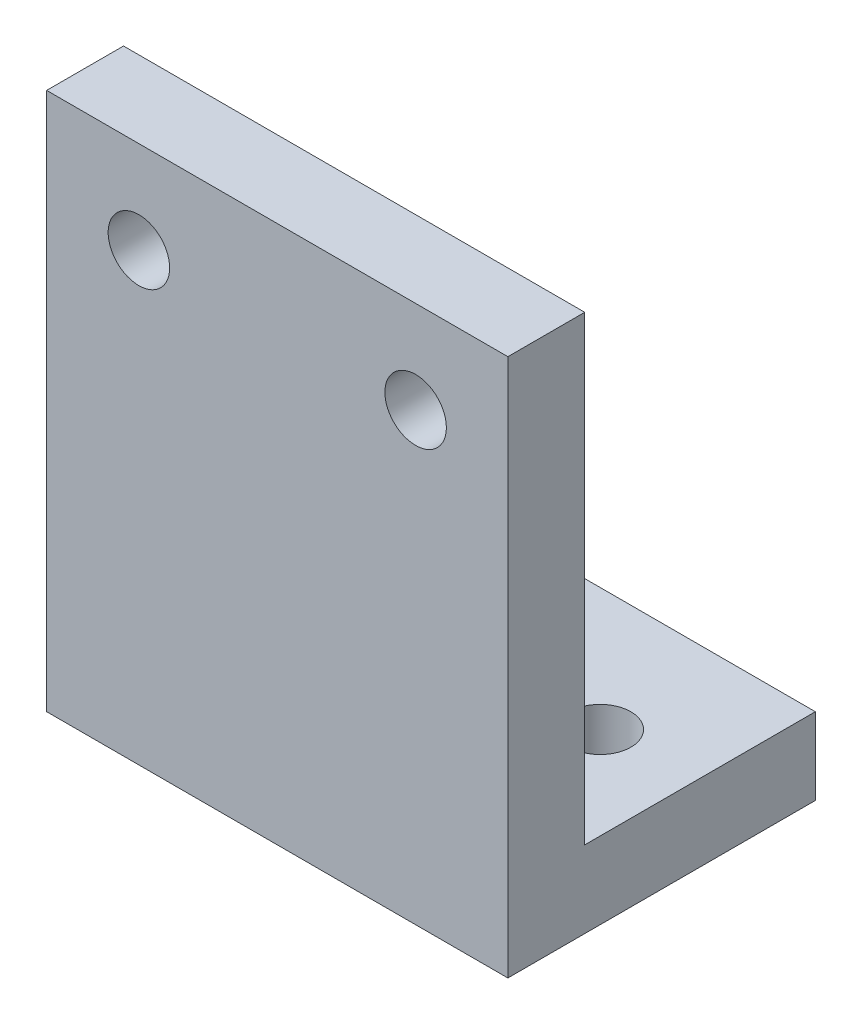
from build123d import *

# Parameters (mm, degrees)
ESBO_O1_W                = 30
ESBO_O1_H                = 30
ESBO_O1_R                = 2
RESSALTO_EXTRUS_O1_DEPTH = 5
ESBO_O2_W                = 30
ESBO_O2_H                = 20
ESBO_O2_R                = 2
RESSALTO_EXTRUS_O2_DEPTH = 5


with BuildPart() as part:
    # Esboço1 → Ressalto-extrusão1 (new body)
    with BuildSketch(Plane.XY):
        Rectangle(ESBO_O1_W, ESBO_O1_H)
        with Locations((-9, 9)):
            Circle(ESBO_O1_R, mode=Mode.SUBTRACT)
        with Locations((9, 9)):
            Circle(ESBO_O1_R, mode=Mode.SUBTRACT)
    extrude(amount=RESSALTO_EXTRUS_O1_DEPTH)

    # Esboço2 → Ressalto-extrusão2 (add)
    with BuildSketch(Plane.XZ.offset(15)):
        with Locations((0, -5)):
            Rectangle(ESBO_O2_W, ESBO_O2_H)
        with Locations((-9, -7)):
            Circle(ESBO_O2_R, mode=Mode.SUBTRACT)
        with Locations((9, -7)):
            Circle(ESBO_O2_R, mode=Mode.SUBTRACT)
    extrude(amount=RESSALTO_EXTRUS_O2_DEPTH)


solid = part.part
